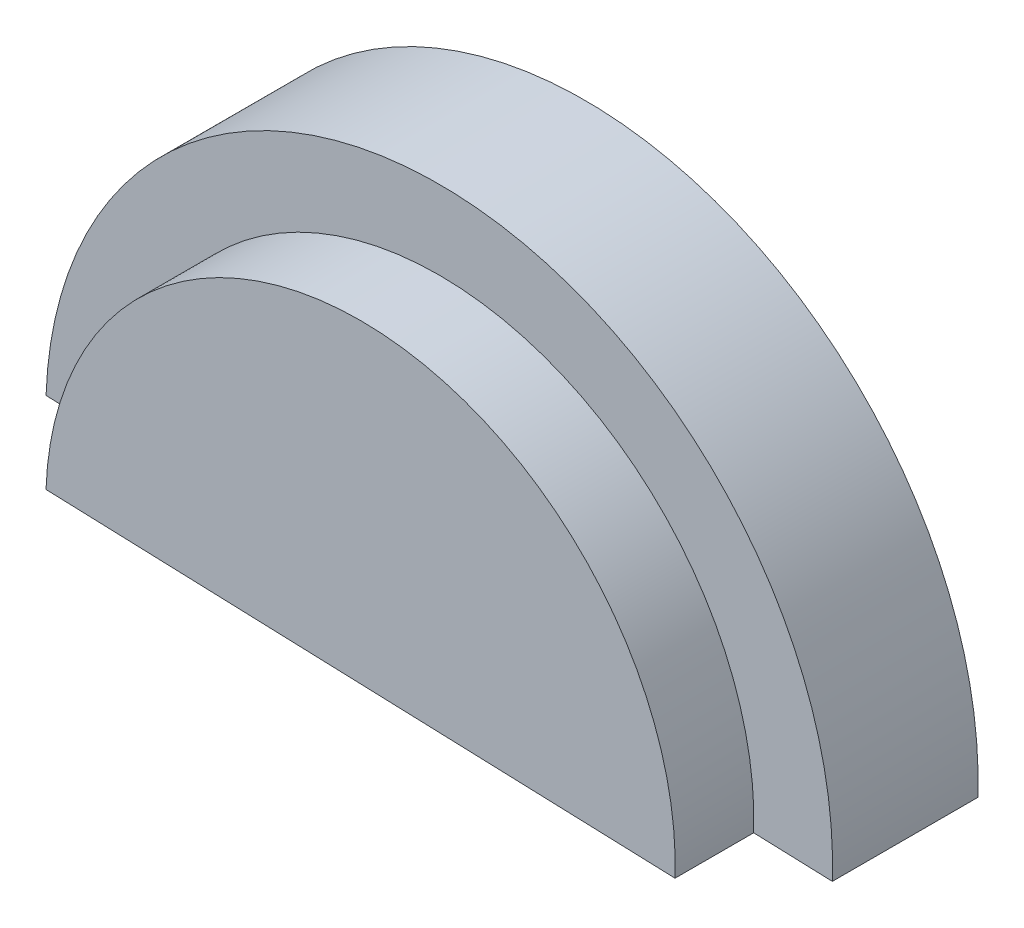
from build123d import *

# Parameters (mm, degrees)
BOSS_EXTRU_1_DEPTH = 185
BOSS_EXTRU_2_DEPTH = 100


with BuildPart() as part:
    # Esquisse1 → Boss.-Extru.1 (new body)
    with BuildSketch(Plane.XY):
        with BuildLine():
            Line((0, 0), (999.380374741, -35.197536598))
            ThreePointArc((999.380374741, -35.197536598), (517.288955669, 482.091419072), (0, 0))
        make_face()
    extrude(amount=BOSS_EXTRU_1_DEPTH)

    # Esquisse3 → Boss.-Extru.2 (add)
    with BuildSketch(Plane.XY.offset(185)):
        with BuildLine():
            Line((99.938037474, -3.51975366), (899.442337267, -31.677782938))
            ThreePointArc((899.442337267, -31.677782938), (513.76920201, 382.153381597), (99.938037474, -3.51975366))
        make_face()
    extrude(amount=BOSS_EXTRU_2_DEPTH)


solid = part.part
